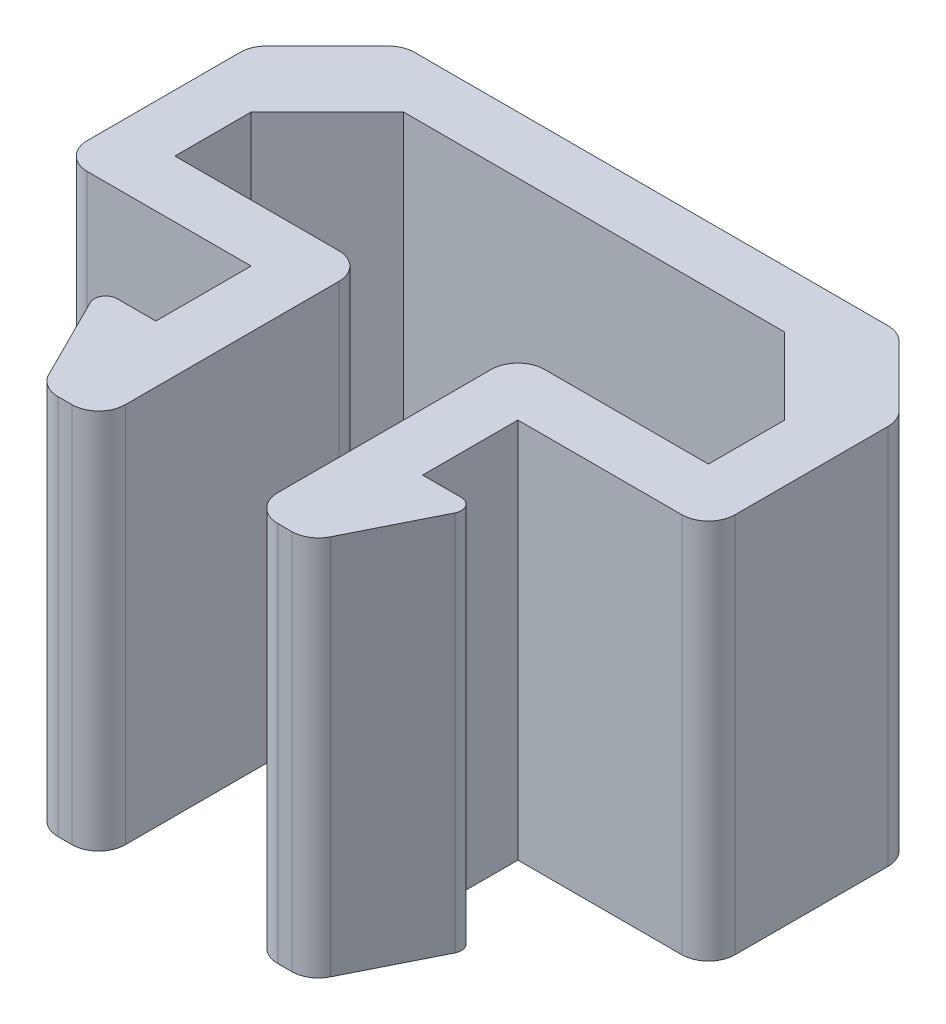
from build123d import *

# Parameters (mm, degrees)
BOSS_EXTRUDE1_DEPTH = 10
CHAMFER1_SIZE       = 2
FILLET1_R           = 0.7
FILLET2_R           = 0.3


with BuildPart() as part:
    # Sketch1 → Boss-Extrude1 (new body)
    with BuildSketch(Plane(origin=(0, 0, 0), x_dir=(1, 0, 0), z_dir=(0, 1, 0))):
        Polygon((-1.7, -14.845158122), (-1.7, -7.845158122), (-6.7, -7.845158122), (-6.7, -3.845158122), (7.3, -3.845158122), (7.3, -7.845158122), (2.3, -7.845158122), (2.3, -14.845158122), (3.8, -14.845158122), (5.3, -11.845158122), (3.8, -11.845158122), (3.8, -9.345158122), (8.8, -9.345158122), (8.8, -2.345158122), (-8.2, -2.345158122), (-8.2, -9.345158122), (-3.2, -9.345158122), (-3.2, -11.845158122), (-4.7, -11.845158122), (-3.2, -14.845158122), align=None)
    extrude(amount=BOSS_EXTRUDE1_DEPTH)

    # Chamfer1
    chamfer1_edges = [part.edges().sort_by_distance(p)[0] for p in [
        (-8.2, 5, 2.345158122),
        (8.8, 5, 2.345158122),
        (7.3, 5, 3.845158122),
        (-6.7, 5, 3.845158122),
    ]]
    chamfer(chamfer1_edges, length=CHAMFER1_SIZE)

    # Fillet1
    fillet1_edges = [part.edges().sort_by_distance(p)[0] for p in [
        (-1.7, 5, 14.845158122),
        (-3.2, 5, 14.845158122),
        (-8.2, 5, 9.345158122),
        (8.8, 5, 9.345158122),
        (3.8, 5, 14.845158122),
        (2.3, 5, 14.845158122),
        (2.3, 5, 7.845158122),
        (-1.7, 5, 7.845158122),
        (-8.2, 5, 4.345158122),
        (6.8, 5, 2.345158122),
        (-6.2, 5, 2.345158122),
        (8.8, 5, 4.345158122),
    ]]
    fillet(fillet1_edges, radius=FILLET1_R)

    # Fillet2
    fillet2_edges = [part.edges().sort_by_distance(p)[0] for p in [
        (-4.7, 5, 11.845158122),
        (5.3, 5, 11.845158122),
    ]]
    fillet(fillet2_edges, radius=FILLET2_R)


solid = part.part
